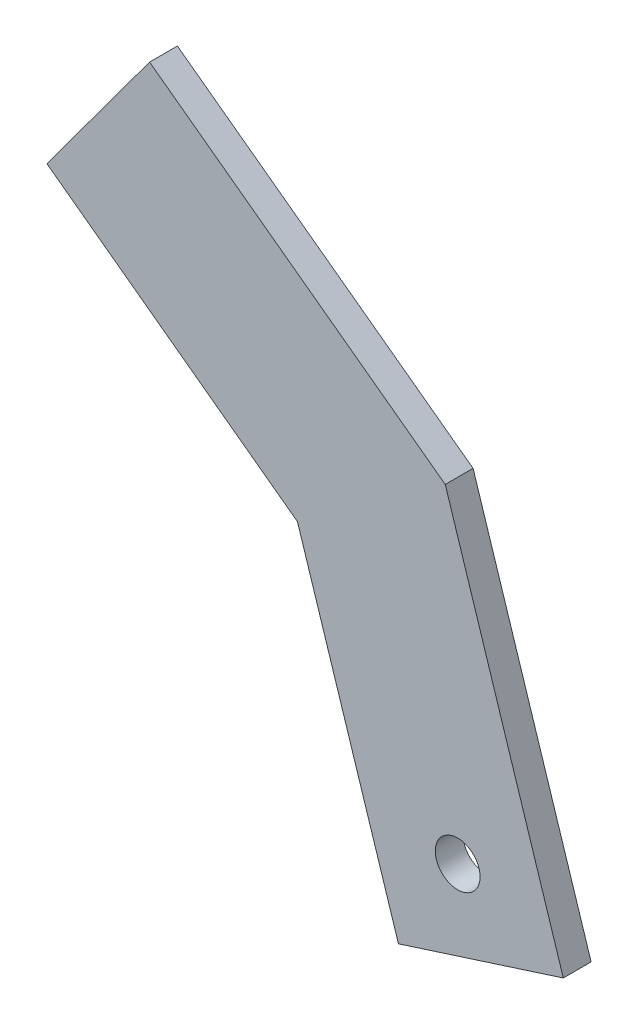
from build123d import *

# Parameters (mm, degrees)
SKETCH1_R           = 16.102619951
BOSS_EXTRUDE1_DEPTH = 20


with BuildPart() as part:
    # Sketch1 → Boss-Extrude1 (new body)
    with BuildSketch(Plane.XY):
        Polygon((-8.926586958, 231.72006077), (75.912753088, -33.053677171), (-42.566229627, -71.016953971), (-115.128312507, 155.440888661), (-295.223128237, 288.175370388), (-221.409823019, 388.325636006), align=None)
        Circle(SKETCH1_R, mode=Mode.SUBTRACT)
    extrude(amount=BOSS_EXTRUDE1_DEPTH)


solid = part.part
